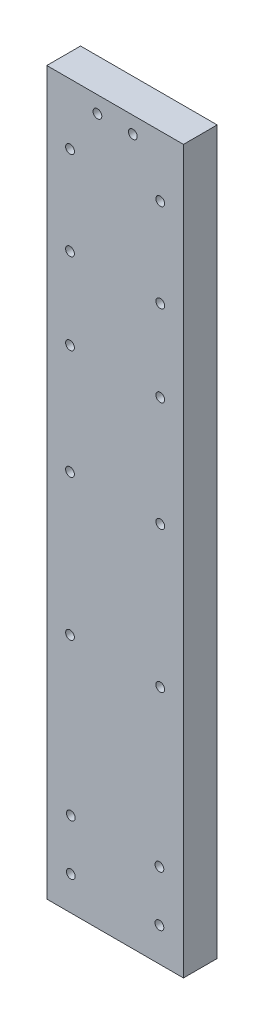
from build123d import *

# Parameters (mm, degrees)
SKETCH1_W           = 16.2
SKETCH1_H           = 85.59
SKETCH1_R           = 0.519960121
BOSS_EXTRUDE1_DEPTH = 4


with BuildPart() as part:
    # Sketch1 → Boss-Extrude1 (new body)
    with BuildSketch(Plane.XY):
        with Locations((8.1, 42.795)):
            Rectangle(SKETCH1_W, SKETCH1_H)
        with Locations((13.45, 45.24)):
            Circle(SKETCH1_R, mode=Mode.SUBTRACT)
        with Locations((2.75, 67.885)):
            Circle(SKETCH1_R, mode=Mode.SUBTRACT)
        with Locations((13.45, 58.24)):
            Circle(SKETCH1_R, mode=Mode.SUBTRACT)
        with Locations((13.45, 78.385)):
            Circle(SKETCH1_R, mode=Mode.SUBTRACT)
        with Locations((2.75, 28.5)):
            Circle(SKETCH1_R, mode=Mode.SUBTRACT)
        with Locations((2.75, 78.385)):
            Circle(SKETCH1_R, mode=Mode.SUBTRACT)
        with Locations((2.75, 58.24)):
            Circle(SKETCH1_R, mode=Mode.SUBTRACT)
        with Locations((2.85, 10)):
            Circle(SKETCH1_R, mode=Mode.SUBTRACT)
        with Locations((13.35, 10)):
            Circle(SKETCH1_R, mode=Mode.SUBTRACT)
        with Locations((13.35, 4)):
            Circle(SKETCH1_R, mode=Mode.SUBTRACT)
        with Locations((2.85, 4)):
            Circle(SKETCH1_R, mode=Mode.SUBTRACT)
        with Locations((6, 83.635)):
            Circle(SKETCH1_R, mode=Mode.SUBTRACT)
        with Locations((13.45, 28.5)):
            Circle(SKETCH1_R, mode=Mode.SUBTRACT)
        with Locations((13.45, 67.885)):
            Circle(SKETCH1_R, mode=Mode.SUBTRACT)
        with Locations((10.2, 83.635)):
            Circle(SKETCH1_R, mode=Mode.SUBTRACT)
        with Locations((2.75, 45.24)):
            Circle(SKETCH1_R, mode=Mode.SUBTRACT)
    extrude(amount=BOSS_EXTRUDE1_DEPTH)


solid = part.part
